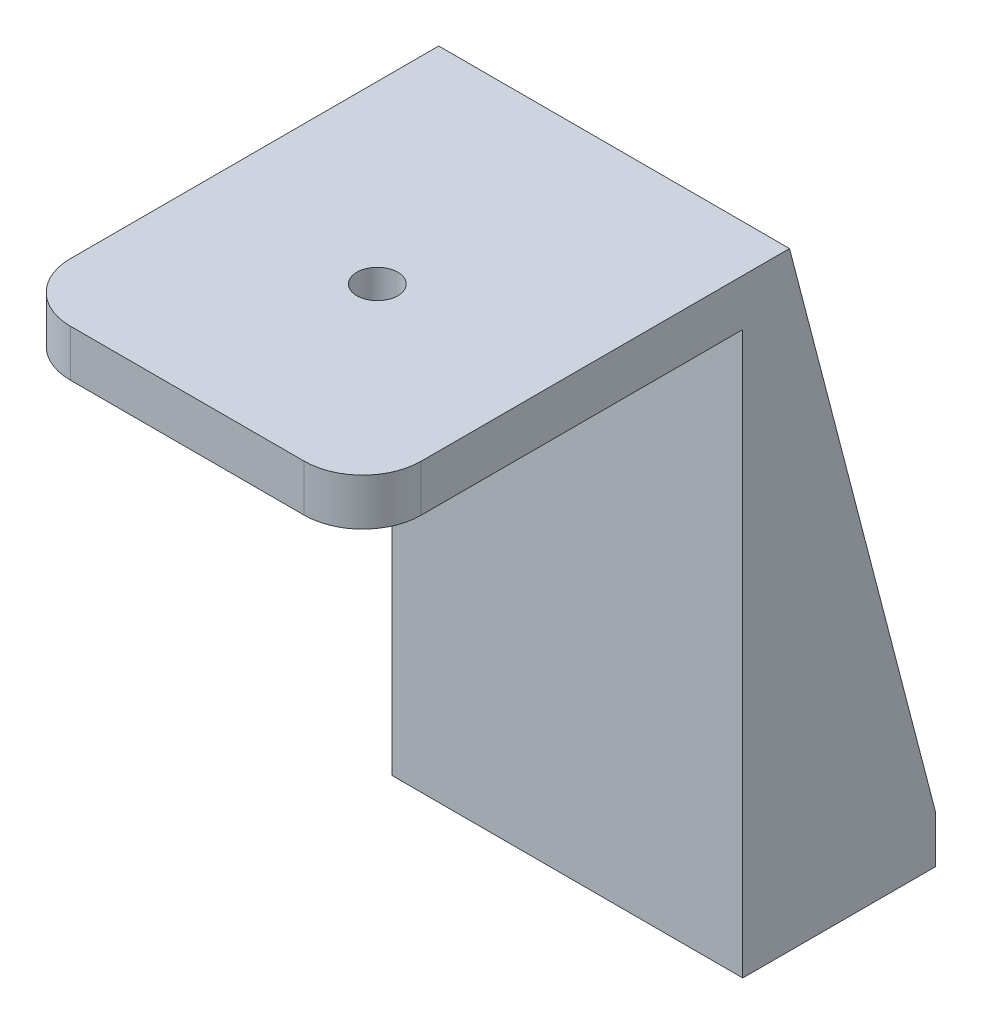
from build123d import *

# Parameters (mm, degrees)
SKETCH1_W           = 60
SKETCH1_H           = 65
BOSS_EXTRUDE1_DEPTH = 8
SKETCH2_R           = 19.05
CUT_EXTRUDE1_DEPTH  = 1.6
SKETCH3_R           = 3.5
CUT_EXTRUDE2_DEPTH  = 7.4
SKETCH4_W           = 60
SKETCH4_H           = 8
BOSS_EXTRUDE2_DEPTH = 104.05
FILLET1_R           = 10
SKETCH5_W           = 60
SKETCH5_H           = 8
BOSS_EXTRUDE3_DEPTH = 25
BOSS_EXTRUDE4_DEPTH = 5


with BuildPart() as part:
    # Sketch1 → Boss-Extrude1 (new body)
    with BuildSketch(Plane(origin=(0, 0, 0), x_dir=(1, 0, 0), z_dir=(0, 1, 0))):
        Rectangle(SKETCH1_W, SKETCH1_H)
    extrude(amount=BOSS_EXTRUDE1_DEPTH)

    # Sketch2 → Cut-Extrude1 (cut)
    with BuildSketch(Plane.XZ):
        Circle(SKETCH2_R)
    extrude(amount=-CUT_EXTRUDE1_DEPTH, mode=Mode.SUBTRACT)

    # Sketch3 → Cut-Extrude2 (cut, through all)
    with BuildSketch(Plane.XZ.offset(-1.6)):
        Circle(SKETCH3_R)
    extrude(amount=-CUT_EXTRUDE2_DEPTH, mode=Mode.SUBTRACT)

    # Sketch4 → Boss-Extrude2 (add)
    with BuildSketch(Plane(origin=(0, 8, 0), x_dir=(1, 0, 0), z_dir=(0, 1, 0))):
        with Locations((0, 36.5)):
            Rectangle(SKETCH4_W, SKETCH4_H)
    extrude(amount=-BOSS_EXTRUDE2_DEPTH)

    # Fillet1
    fillet1_edges = [part.edges().sort_by_distance(p)[0] for p in [
        (-30, 4, 32.5),
        (30, 4, 32.5),
    ]]
    fillet(fillet1_edges, radius=FILLET1_R)

    # Sketch5 → Boss-Extrude3 (add)
    with BuildSketch(Plane(origin=(0, 0, -40.5), x_dir=(-1, 0, 0), z_dir=(0, 0, -1))):
        with Locations((0, -92.05)):
            Rectangle(SKETCH5_W, SKETCH5_H)
    extrude(amount=BOSS_EXTRUDE3_DEPTH)

    # Sketch6 → Boss-Extrude4 (add)
    with BuildSketch(Plane(origin=(30, 0, 0), x_dir=(0, 0, -1), z_dir=(1, 0, 0))):
        Polygon((40.5, 8), (65.5, -88.05), (40.5, -88.05), align=None)
    boss_extrude4 = extrude(amount=-BOSS_EXTRUDE4_DEPTH)

    # Mirror1: Boss-Extrude4 across plane
    add(boss_extrude4.mirror(Plane(origin=(0, 0, 0), x_dir=(0, 0, 1), z_dir=(1, 0, 0))))


solid = part.part
